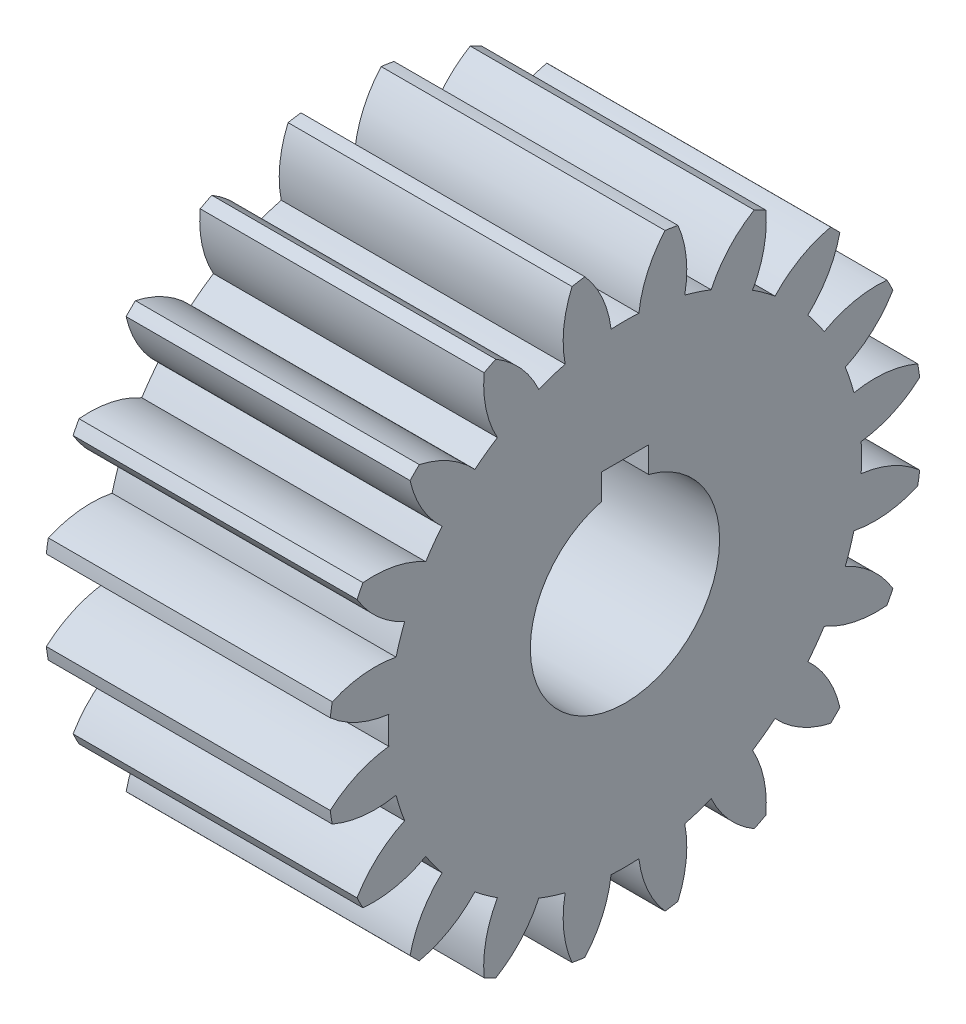
from build123d import *

# Parameters (mm, degrees)
BASPROSKE_W             = 19.05
BASPROSKE_H             = 19.957142857
TOOTHCUT_DEPTH          = 35.051102802
TEETHCUTS_COUNT         = 20
BORSKE_R                = 6.35
BORE_DEPTH              = 50.8000508
KEYSKE_W                = 3.175
KEYSKE_H                = 7.4676
KEYWAY_DEPTH            = 50.8000508
SKETCH1_W               = 3.175
SKETCH1_H               = 0.4064
CUT_EXTRUDE4_DEPTH      = 34.838053031
CUT_EXTRUDE4_DEPTH_BACK = 34.838053031


with BuildPart() as part:
    # BasProSke → Base-Revolve (revolve)
    with BuildSketch(Plane(origin=(0, 0, 0), x_dir=(1, 0, 0), z_dir=(0, 1, 0)), mode=Mode.PRIVATE) as base_revolve_sk:
        with Locations((9.525, 9.978571429)):
            Rectangle(BASPROSKE_W, BASPROSKE_H)
    revolve(base_revolve_sk.sketch.rotate(Axis((-10, 0, 0), (1, 0, 0)), 180), axis=Axis((-10, 0, 0), (1, 0, 0)))

    # TooCutSke → ToothCut (cut, through all)
    with BuildSketch(Plane(origin=(0, 0, 0), x_dir=(0, 0, -1), z_dir=(1, 0, 0))):
        with BuildLine():
            ThreePointArc((0.93220263, 15.846334036), (0, 15.87373), (-0.93220263, 15.846334036))
            ThreePointArc((-0.93220263, 15.846334036), (-1.519014467, 17.957902446), (-2.709431151, 19.798004997))
            ThreePointArc((-2.709431151, 19.798004997), (0, 19.982542857), (2.709431151, 19.798004997))
            ThreePointArc((2.709431151, 19.798004997), (1.519014467, 17.957902446), (0.93220263, 15.846334036))
        make_face()
    toothcut = extrude(amount=TOOTHCUT_DEPTH, mode=Mode.SUBTRACT)

    # TeethCuts: ToothCut ×20 about axis
    teethcuts_axis = Axis((0, 0, 0), (1, 0, 0))
    for i in range(1, TEETHCUTS_COUNT):
        add(toothcut.rotate(teethcuts_axis, i * 360 / TEETHCUTS_COUNT), mode=Mode.SUBTRACT)

    # BorSke → Bore (cut, symmetric)
    with BuildSketch(Plane(origin=(0, 0, 0), x_dir=(0, 0, -1), z_dir=(1, 0, 0))):
        with Locations(Location((0, 0, 0), (0, 0, 180))):
            Circle(BORSKE_R)
    extrude(amount=BORE_DEPTH, both=True, mode=Mode.SUBTRACT)

    # KeySke → Keyway (cut, symmetric)
    with BuildSketch(Plane(origin=(0, 0, 0), x_dir=(0, 0, -1), z_dir=(1, 0, 0))):
        with Locations((0, 3.7338)):
            Rectangle(KEYSKE_W, KEYSKE_H)
    extrude(amount=KEYWAY_DEPTH, both=True, mode=Mode.SUBTRACT)

    # Sketch1 → Cut-Extrude4 (cut, two sides)
    with BuildSketch(Plane(origin=(19.05, 0, 0), x_dir=(0, 0, -1), z_dir=(1, 0, 0))) as cut_extrude4_sk:
        with Locations((0, 7.6708)):
            Rectangle(SKETCH1_W, SKETCH1_H)
    extrude(amount=CUT_EXTRUDE4_DEPTH, mode=Mode.SUBTRACT)
    extrude(cut_extrude4_sk.sketch, amount=-CUT_EXTRUDE4_DEPTH_BACK, mode=Mode.SUBTRACT)


solid = part.part
